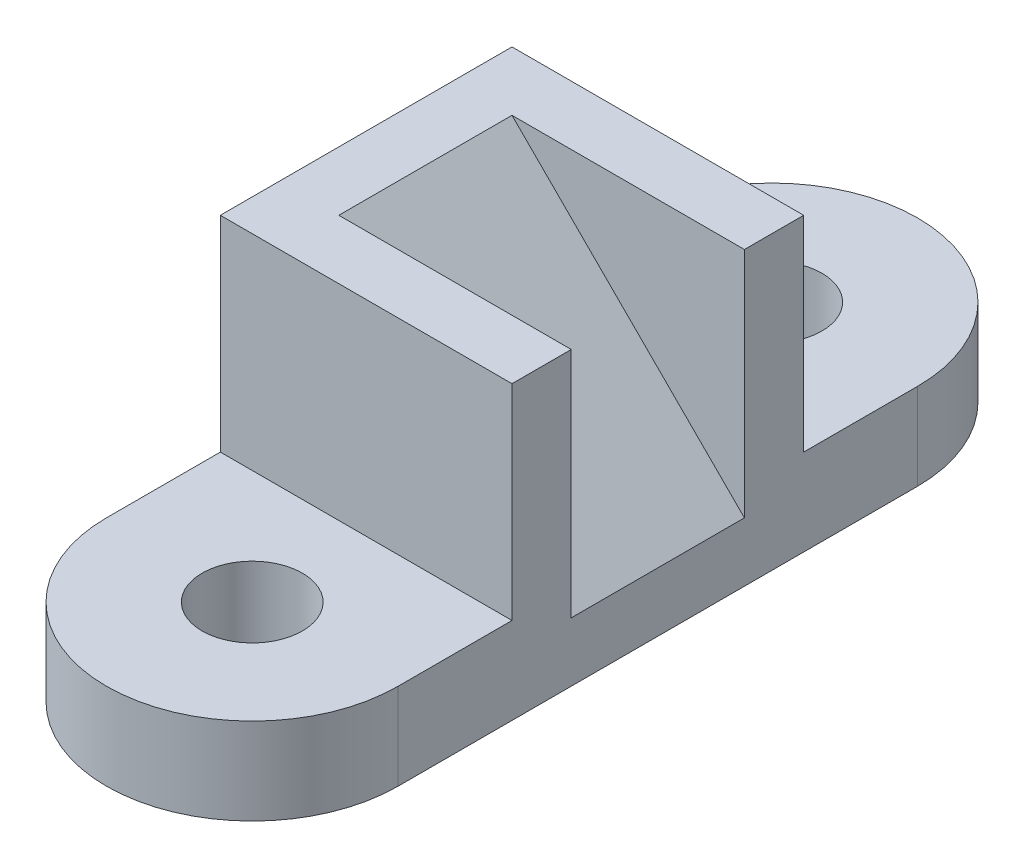
from build123d import *

# Parameters (mm, degrees)
IZIM1_R                     = 11
Y_KSEKLIK_EKSTR_ZYON1_DEPTH = 19
Y_KSEKLIK_EKSTR_ZYON2_DEPTH = 45
IZIM3_W                     = 51
IZIM3_H                     = 38
KES_EKSTR_ZYON1_DEPTH       = 6
Y_KSEKLIK_EKSTR_ZYON3_DEPTH = 38


with BuildPart() as part:
    # Çizim1 → Yükseklik-Ekstrüzyon1 (new body)
    with BuildSketch(Plane(origin=(0, 0, 0), x_dir=(1, 0, 0), z_dir=(0, 1, 0))):
        with BuildLine():
            Line((32, 57), (32, -57))
            ThreePointArc((32, -57), (0, -89), (-32, -57))
            Line((-32, -57), (-32, 57))
            ThreePointArc((-32, 57), (0, 89), (32, 57))
        make_face()
        with Locations((0, -57)):
            Circle(IZIM1_R, mode=Mode.SUBTRACT)
        with Locations((0, 57)):
            Circle(IZIM1_R, mode=Mode.SUBTRACT)
    extrude(amount=Y_KSEKLIK_EKSTR_ZYON1_DEPTH)

    # Çizim2 → Yükseklik-Ekstrüzyon2 (add)
    with BuildSketch(Plane(origin=(0, 19, 0), x_dir=(1, 0, 0), z_dir=(0, 1, 0))):
        Polygon((32, 32), (-32, 32), (-32, 26.829629141), (-32, -32), (-22.456517783, -32), (32, -32), (32, -19), (-19, -19), (-19, 19), (32, 19), align=None)
    extrude(amount=Y_KSEKLIK_EKSTR_ZYON2_DEPTH)

    # Çizim3 → Kes-Ekstrüzyon1 (cut)
    with BuildSketch(Plane(origin=(0, 19, 0), x_dir=(1, 0, 0), z_dir=(0, 1, 0))):
        with Locations((6.5, 0)):
            Rectangle(IZIM3_W, IZIM3_H)
    extrude(amount=-KES_EKSTR_ZYON1_DEPTH, mode=Mode.SUBTRACT)

    # Çizim4 → Yükseklik-Ekstrüzyon3 (add)
    with BuildSketch(Plane.XY.offset(-19)):
        Polygon((-19, 64), (32, 13), (-19, 13), align=None)
    extrude(amount=Y_KSEKLIK_EKSTR_ZYON3_DEPTH)


solid = part.part
